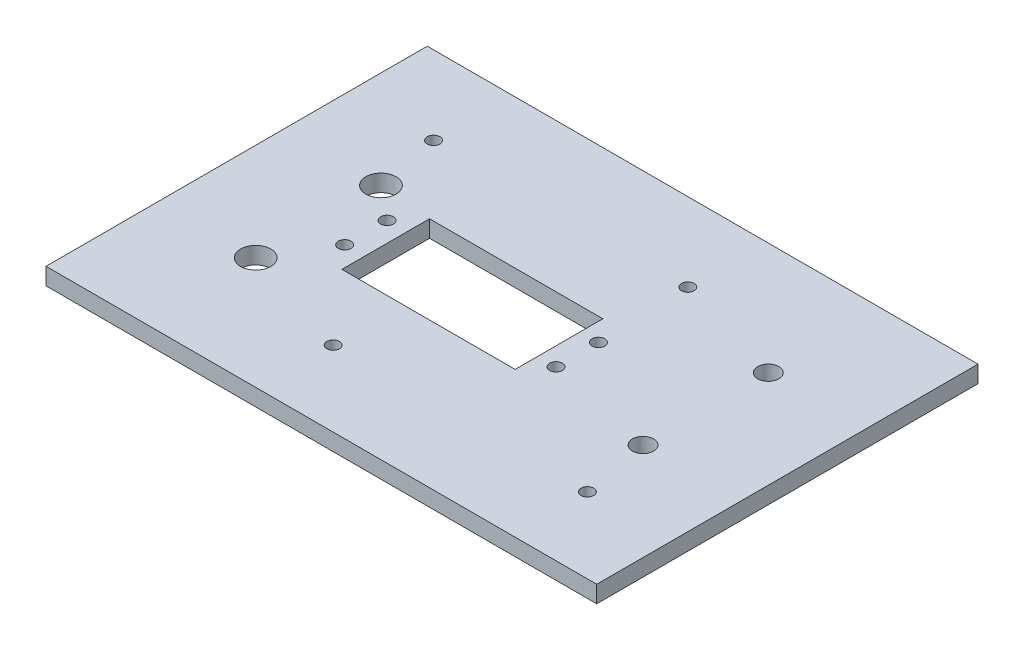
from build123d import *

# Parameters (mm, degrees)
SKETCH1_W           = 130
SKETCH1_H           = 90
BOSS_EXTRUDE1_DEPTH = 4
SKETCH7_R           = 3.65
SKETCH7_R_2         = 3.57
CUT_EXTRUDE5_DEPTH  = 10
SKETCH15_W          = 40.9
SKETCH15_H          = 20.7
CUT_EXTRUDE10_DEPTH = 5
SKETCH6_R           = 1.5
CUT_EXTRUDE4_DEPTH  = 4
SKETCH12_R          = 1.5
CUT_EXTRUDE8_DEPTH  = 5
SKETCH14_W          = 15.685038152
SKETCH14_H          = 44.965808151
SKETCH14_R          = 2.5
BOSS_EXTRUDE2_DEPTH = 4


with BuildPart() as part:
    # Sketch1 → Boss-Extrude1 (new body)
    with BuildSketch(Plane(origin=(0, 0, 0), x_dir=(1, 0, 0), z_dir=(0, 1, 0))):
        with Locations((-40, -6.672366697)):
            Rectangle(SKETCH1_W, SKETCH1_H)
    extrude(amount=BOSS_EXTRUDE1_DEPTH)

    # Sketch7 → Cut-Extrude5 (cut)
    with BuildSketch(Plane(origin=(0, 4, 0), x_dir=(1, 0, 0), z_dir=(0, 1, 0))):
        with Locations((2, 11.827633303)):
            Circle(SKETCH7_R)
        with Locations((2, -17.738049342)):
            Circle(SKETCH7_R)
        with Locations((-82, 4.393315947)):
            Circle(SKETCH7_R_2)
        with Locations((-82, -25.172366697)):
            Circle(SKETCH7_R_2)
    extrude(amount=-CUT_EXTRUDE5_DEPTH, mode=Mode.SUBTRACT)

    # Sketch15 → Cut-Extrude10 (cut, through all)
    with BuildSketch(Plane(origin=(0, 4, 0), x_dir=(1, 0, 0), z_dir=(0, 1, 0))):
        with Locations((-49, -7.030465848)):
            Rectangle(SKETCH15_W, SKETCH15_H)
    extrude(amount=-CUT_EXTRUDE10_DEPTH, mode=Mode.SUBTRACT)

    # Sketch6 → Cut-Extrude4 (cut)
    with BuildSketch(Plane.XZ):
        with Locations((-74.139435372, 12.030465848)):
            Circle(SKETCH6_R)
        with Locations((-24.239435372, 12.030465848)):
            Circle(SKETCH6_R)
        with Locations((-74.139435372, 2.030465848)):
            Circle(SKETCH6_R)
        with Locations((-24.239435372, 2.030465848)):
            Circle(SKETCH6_R)
    extrude(amount=-CUT_EXTRUDE4_DEPTH, mode=Mode.SUBTRACT)

    # Sketch12 → Cut-Extrude8 (cut, through all)
    with BuildSketch(Plane(origin=(0, 4, 0), x_dir=(1, 0, 0), z_dir=(0, 1, 0))):
        with Locations((-85, 19.819534152)):
            Circle(SKETCH12_R)
        with Locations((-25, 19.819534152)):
            Circle(SKETCH12_R)
        with Locations((-55, -33.880465848)):
            Circle(SKETCH12_R)
        with Locations((5, -33.880465848)):
            Circle(SKETCH12_R)
    extrude(amount=-CUT_EXTRUDE8_DEPTH, mode=Mode.SUBTRACT)

    # Sketch14 → Boss-Extrude2 (add, through all)
    with BuildSketch(Plane(origin=(0, 4, 0), x_dir=(1, 0, 0), z_dir=(0, 1, 0))):
        with Locations((2, -2.95520802)):
            Rectangle(SKETCH14_W, SKETCH14_H)
        with Locations((2, 11.827633303)):
            Circle(SKETCH14_R, mode=Mode.SUBTRACT)
        with Locations((2, -17.738049342)):
            Circle(SKETCH14_R, mode=Mode.SUBTRACT)
    extrude(amount=-BOSS_EXTRUDE2_DEPTH)


solid = part.part
